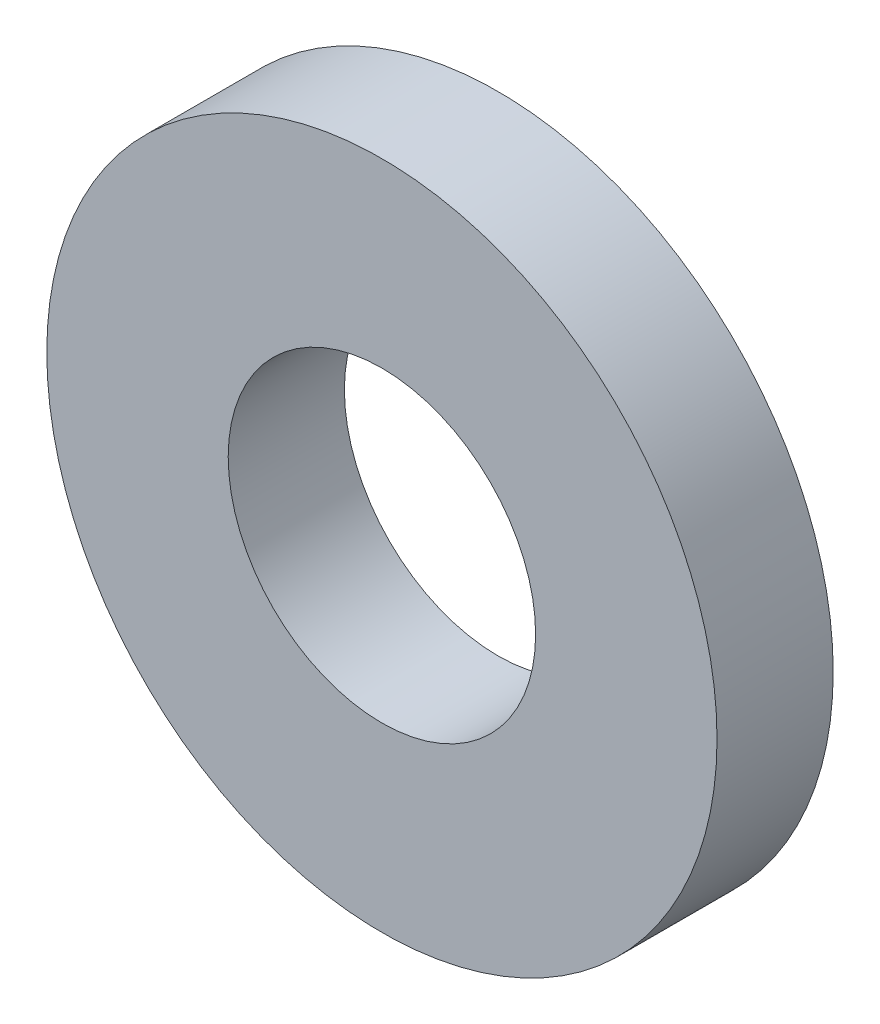
from build123d import *

# Parameters (mm, degrees)
SKETCH1_R      = 4.7625
SKETCH1_R_2    = 2.1844
EXTRUDE1_DEPTH = 1.651


with BuildPart() as part:
    # Sketch1 → Extrude1 (new body)
    with BuildSketch(Plane.XY):
        Circle(SKETCH1_R)
        Circle(SKETCH1_R_2, mode=Mode.SUBTRACT)
    extrude(amount=EXTRUDE1_DEPTH)


solid = part.part
